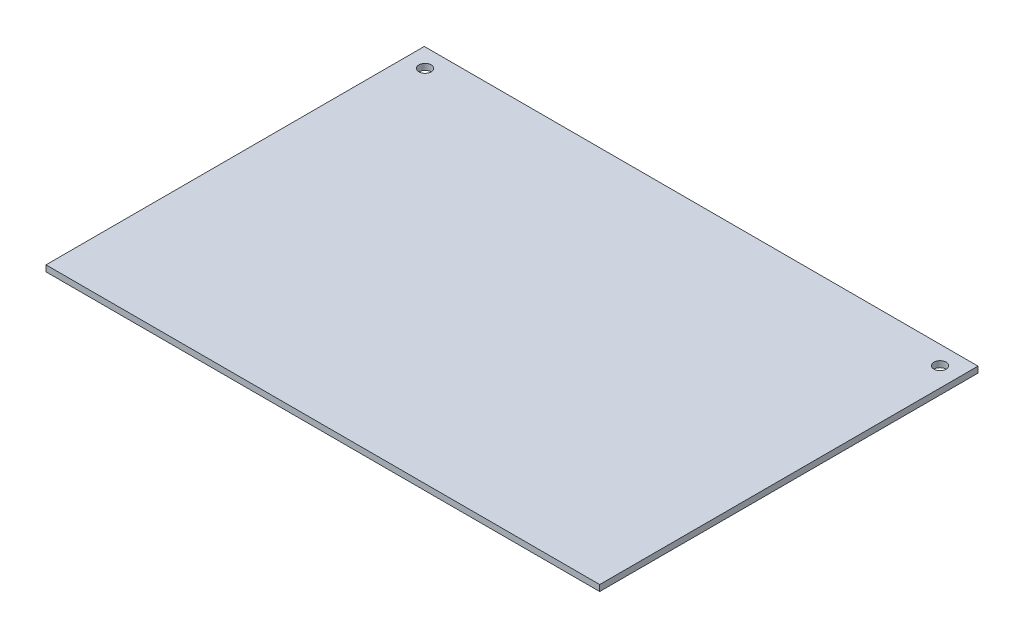
from build123d import *

# Parameters (mm, degrees)
SKETCH1_W           = 181.5
SKETCH1_H           = 124
BOSS_EXTRUDE1_DEPTH = 2
SKETCH3_R           = 2
CUT_EXTRUDE1_DEPTH  = 3


with BuildPart() as part:
    # Sketch1 → Boss-Extrude1 (new body)
    with BuildSketch(Plane(origin=(0, 0, 0), x_dir=(1, 0, 0), z_dir=(0, 1, 0))):
        Rectangle(SKETCH1_W, SKETCH1_H)
    extrude(amount=BOSS_EXTRUDE1_DEPTH)

    # Sketch3 → Cut-Extrude1 (cut, through all)
    with BuildSketch(Plane(origin=(0, 2, 0), x_dir=(1, 0, 0), z_dir=(0, 1, 0))):
        with Locations((-84.400671125, 55.905118791)):
            Circle(SKETCH3_R)
        with Locations((84.400671125, 55.905118791)):
            Circle(SKETCH3_R)
    extrude(amount=-CUT_EXTRUDE1_DEPTH, mode=Mode.SUBTRACT)


solid = part.part
